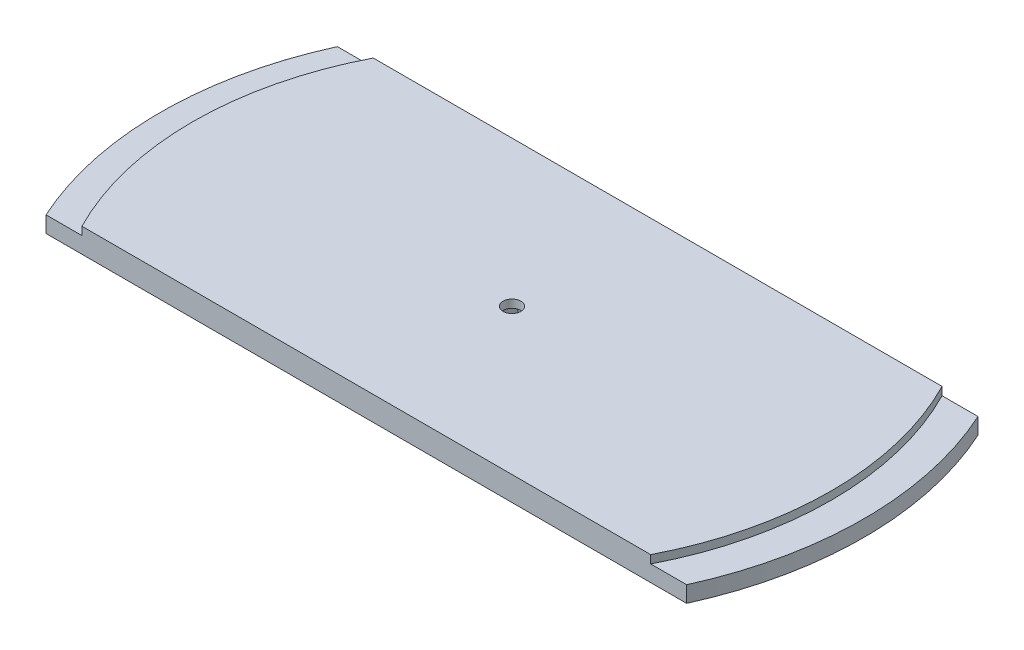
from build123d import *

# Parameters (mm, degrees)
BOSS_EXTRUDE1_DEPTH = 9.525
BOSS_EXTRUDE2_DEPTH = 6.35
BOSS_EXTRUDE3_START = 6.35
SKETCH1_4_R         = 3.4925
BOSS_EXTRUDE3_DEPTH = 3.175


with BuildPart() as part:
    # Sketch1 → Boss-Extrude1 (new body)
    with BuildSketch(Plane(origin=(0, 0, 0), x_dir=(1, 0, 0), z_dir=(0, 1, 0))):
        with BuildLine():
            Line((111.562759472, 57.15), (-111.562759472, 57.15))
            ThreePointArc((-111.562759472, 57.15), (-125.349, 0), (-111.562759472, -57.15))
            Line((-111.562759472, -57.15), (111.562759472, -57.15))
            ThreePointArc((111.562759472, -57.15), (125.349, 0), (111.562759472, 57.15))
        make_face()
        Polygon((-3.299556788, -5.715), (-6.599113577, 0), (-3.299556788, 5.715), (3.299556788, 5.715), (6.599113577, 0), (3.299556788, -5.715), align=None, mode=Mode.SUBTRACT)
    extrude(amount=BOSS_EXTRUDE1_DEPTH)

    # Sketch1_3 → Boss-Extrude2 (add)
    with BuildSketch(Plane(origin=(0, 0, 0), x_dir=(1, 0, 0), z_dir=(0, 1, 0))):
        with BuildLine():
            Line((-111.562759472, 57.15), (-125.663852802, 57.15))
            ThreePointArc((-125.663852802, 57.15), (-138.049, 0), (-125.663852802, -57.15))
            Line((-125.663852802, -57.15), (-111.562759472, -57.15))
            ThreePointArc((-111.562759472, -57.15), (-125.349, 0), (-111.562759472, 57.15))
        make_face()
        with BuildLine():
            Line((125.663852802, 57.15), (111.562759472, 57.15))
            ThreePointArc((111.562759472, 57.15), (125.349, 0), (111.562759472, -57.15))
            Line((111.562759472, -57.15), (125.663852802, -57.15))
            ThreePointArc((125.663852802, -57.15), (138.049, 0), (125.663852802, 57.15))
        make_face()
    extrude(amount=BOSS_EXTRUDE2_DEPTH)

    # Sketch1_4 → Boss-Extrude3 (add)
    with BuildSketch(Plane(origin=(0, 0, 0), x_dir=(1, 0, 0), z_dir=(0, 1, 0)).offset(BOSS_EXTRUDE3_START)):
        Polygon((-3.299556788, 5.715), (-6.599113577, 0), (-3.299556788, -5.715), (3.299556788, -5.715), (6.599113577, 0), (3.299556788, 5.715), align=None)
        Circle(SKETCH1_4_R, mode=Mode.SUBTRACT)
    extrude(amount=BOSS_EXTRUDE3_DEPTH)


solid = part.part
